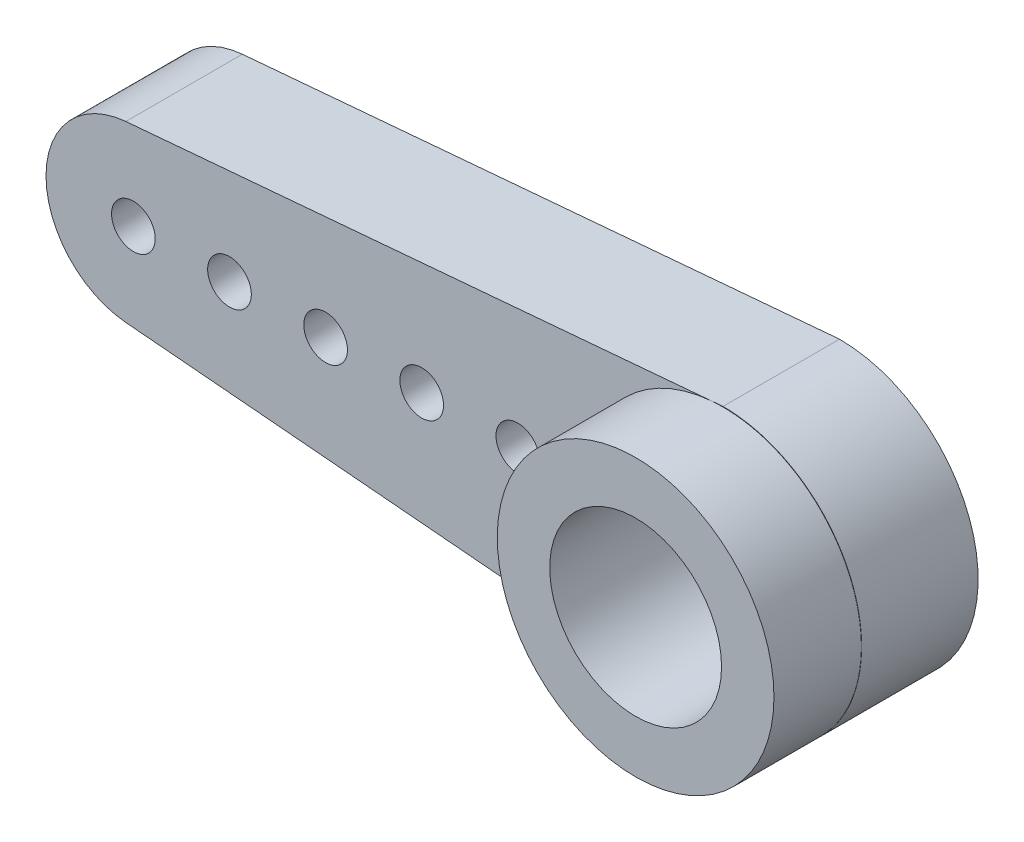
from build123d import *

# Parameters (mm, degrees)
SKETCH1_R           = 2.95
SKETCH1_R_2         = 0.75
BOSS_EXTRUDE1_DEPTH = 4
SKETCH2_R           = 4.75
SKETCH2_R_2         = 2.95
BOSS_EXTRUDE2_DEPTH = 3


with BuildPart() as part:
    # Sketch1 → Boss-Extrude1 (new body)
    with BuildSketch(Plane.XY):
        with BuildLine():
            Line((0, 4.76784671), (-20.504052607, 2.988770585))
            ThreePointArc((-20.504052607, 2.988770585), (-23.244725805, 0), (-20.504052607, -2.988770585))
            Line((-20.504052607, -2.988770585), (-0.41060077, -4.732220093))
            ThreePointArc((-0.41060077, -4.732220093), (4.755274195, -0.196586841), (0, 4.76784671))
        make_face()
        Circle(SKETCH1_R, mode=Mode.SUBTRACT)
        with Locations((-20.244725805, 0)):
            Circle(SKETCH1_R_2, mode=Mode.SUBTRACT)
        with Locations((-16.944725805, 0)):
            Circle(SKETCH1_R_2, mode=Mode.SUBTRACT)
        with Locations((-13.644725805, 0)):
            Circle(SKETCH1_R_2, mode=Mode.SUBTRACT)
        with Locations((-10.344725805, 0)):
            Circle(SKETCH1_R_2, mode=Mode.SUBTRACT)
        with Locations((-7.044725805, 0)):
            Circle(SKETCH1_R_2, mode=Mode.SUBTRACT)
    extrude(amount=BOSS_EXTRUDE1_DEPTH)

    # Sketch2 → Boss-Extrude2 (add)
    with BuildSketch(Plane.XY.offset(4)):
        Circle(SKETCH2_R)
        Circle(SKETCH2_R_2, mode=Mode.SUBTRACT)
    extrude(amount=BOSS_EXTRUDE2_DEPTH)


solid = part.part
